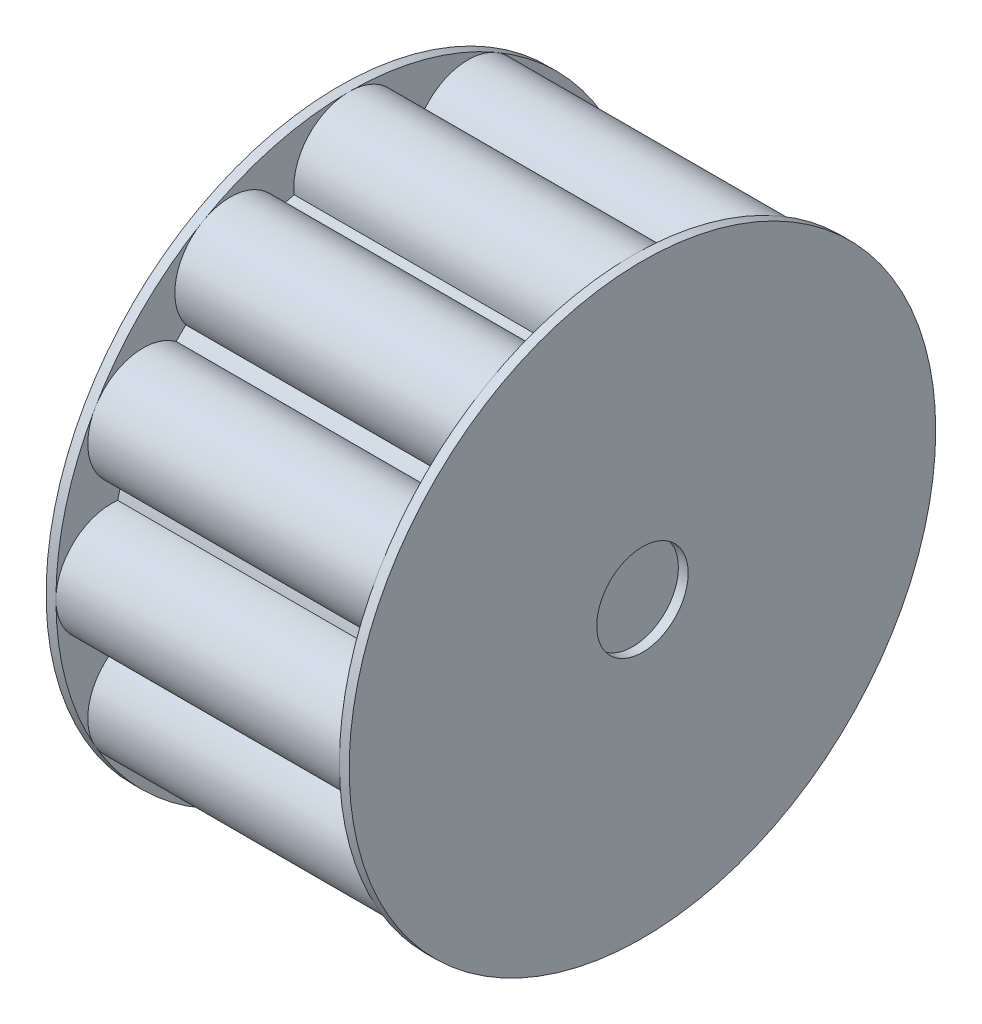
from build123d import *

# Parameters (mm, degrees)
SKETCH1_R           = 30
BOSS_EXTRUDE1_DEPTH = 1
SKETCH2_R           = 24.335851471
BOSS_EXTRUDE2_DEPTH = 29
SKETCH3_R           = 5.664148529
BOSS_EXTRUDE3_DEPTH = 29
SKETCH4_R           = 30
BOSS_EXTRUDE4_DEPTH = 1
SKETCH5_R           = 4.681501742
CUT_EXTRUDE1_DEPTH  = 1
SKETCH6_R           = 4.678679428
CUT_EXTRUDE2_DEPTH  = 1


with BuildPart() as part:
    # Sketch1 → Boss-Extrude1 (new body)
    with BuildSketch(Plane(origin=(0, 0, 0), x_dir=(0, 0, -1), z_dir=(1, 0, 0))):
        Circle(SKETCH1_R)
    extrude(amount=BOSS_EXTRUDE1_DEPTH)

    # Sketch2 → Boss-Extrude2 (add)
    with BuildSketch(Plane(origin=(1, 0, 0), x_dir=(0, 0, -1), z_dir=(1, 0, 0))):
        Circle(SKETCH2_R)
    extrude(amount=BOSS_EXTRUDE2_DEPTH)

    # Sketch3 → Boss-Extrude3 (add)
    with BuildSketch(Plane(origin=(30, 0, 0), x_dir=(0, 0, -1), z_dir=(1, 0, 0))):
        with Locations((0, 24.335851471)):
            Circle(SKETCH3_R)
        with Locations((12.167925735, 21.075465597)):
            Circle(SKETCH3_R)
        with Locations((21.075465597, 12.167925735)):
            Circle(SKETCH3_R)
        with Locations((24.335851471, 0)):
            Circle(SKETCH3_R)
        with Locations((21.075465597, -12.167925735)):
            Circle(SKETCH3_R)
        with Locations((12.167925735, -21.075465597)):
            Circle(SKETCH3_R)
        with Locations((0, -24.335851471)):
            Circle(SKETCH3_R)
        with Locations((-12.167925735, -21.075465597)):
            Circle(SKETCH3_R)
        with Locations((-21.075465597, -12.167925735)):
            Circle(SKETCH3_R)
        with Locations((-24.335851471, 0)):
            Circle(SKETCH3_R)
        with Locations((-21.075465597, 12.167925735)):
            Circle(SKETCH3_R)
        with Locations((-12.167925735, 21.075465597)):
            Circle(SKETCH3_R)
    extrude(amount=-BOSS_EXTRUDE3_DEPTH)

    # Sketch4 → Boss-Extrude4 (add)
    with BuildSketch(Plane(origin=(30, 0, 0), x_dir=(0, 0, -1), z_dir=(1, 0, 0))):
        Circle(SKETCH4_R)
    extrude(amount=BOSS_EXTRUDE4_DEPTH)

    # Sketch5 → Cut-Extrude1 (cut)
    with BuildSketch(Plane.ZY):
        Circle(SKETCH5_R)
    extrude(amount=-CUT_EXTRUDE1_DEPTH, mode=Mode.SUBTRACT)

    # Sketch6 → Cut-Extrude2 (cut)
    with BuildSketch(Plane(origin=(31, 0, 0), x_dir=(0, 0, -1), z_dir=(1, 0, 0))):
        Circle(SKETCH6_R)
    extrude(amount=-CUT_EXTRUDE2_DEPTH, mode=Mode.SUBTRACT)


solid = part.part
